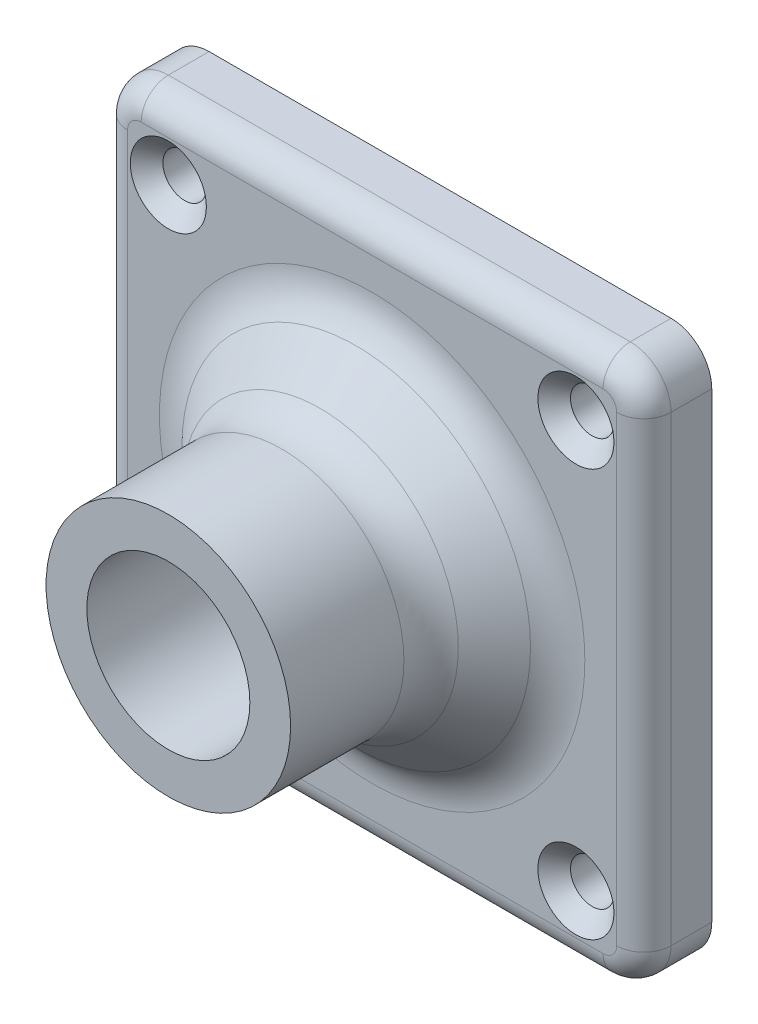
from build123d import *

# Parameters (mm, degrees)
SKETCH2_R           = 9
SKETCH2_R_2         = 6
BOSS_EXTRUDE1_DEPTH = 20
SKETCH3_R           = 6
BOSS_EXTRUDE2_DEPTH = 5
FILLET1_R           = 2
CUT_EXTRUDE1_REACH  = 7
SKETCH4_R           = 1.6
CHAMFER1_SIZE       = 5
FILLET2_R           = 4
CHAMFER2_SIZE       = 1.2


with BuildPart() as part:
    # Sketch2 → Boss-Extrude1 (new body)
    with BuildSketch(Plane.XY):
        with Locations((-135, -82.312657819)):
            Circle(SKETCH2_R)
        with Locations((-135, -82.312657819)):
            Circle(SKETCH2_R_2, mode=Mode.SUBTRACT)
    extrude(amount=BOSS_EXTRUDE1_DEPTH)

    # Sketch3 → Boss-Extrude2 (add)
    with BuildSketch(Plane(origin=(0, 0, 0), x_dir=(-1, 0, 0), z_dir=(0, 0, -1))):
        with BuildLine():
            Line((152, -102.312657819), (118, -102.312657819))
            ThreePointArc((118, -102.312657819), (115.878679656, -101.433978162), (115, -99.312657819))
            Line((115, -99.312657819), (115, -65.312657819))
            ThreePointArc((115, -65.312657819), (115.878679656, -63.191337475), (118, -62.312657819))
            Line((118, -62.312657819), (152, -62.312657819))
            ThreePointArc((152, -62.312657819), (154.121320344, -63.191337475), (155, -65.312657819))
            Line((155, -65.312657819), (155, -99.312657819))
            ThreePointArc((155, -99.312657819), (154.121320344, -101.433978162), (152, -102.312657819))
        make_face()
        with Locations((135, -82.312657819)):
            Circle(SKETCH3_R, mode=Mode.SUBTRACT)
    extrude(amount=-BOSS_EXTRUDE2_DEPTH)

    # Fillet1
    fillet1_edges = [part.edges().sort_by_distance(p)[0] for p in [
        (-115.878679656, -101.433978162, 5),
        (-115, -82.312657819, 5),
        (-115.878679656, -63.191337475, 5),
        (-135, -62.312657819, 5),
        (-154.121320344, -63.191337475, 5),
        (-155, -82.312657819, 5),
        (-154.121320344, -101.433978162, 5),
        (-135, -102.312657819, 5),
    ]]
    fillet(fillet1_edges, radius=FILLET1_R)

    # Sketch4 → Cut-Extrude1 (cut, up to next)
    with BuildSketch(Plane.XY.offset(5), mode=Mode.PRIVATE) as cut_extrude1_sk1:
        with Locations((-150, -67.312657819)):
            Circle(SKETCH4_R)
    cut_extrude1_tool1 = extrude(cut_extrude1_sk1.sketch, amount=-CUT_EXTRUDE1_REACH, mode=Mode.PRIVATE) & part.part
    add(cut_extrude1_tool1.solids().sort_by_distance((-150, -67.312658, 5))[0], mode=Mode.SUBTRACT)
    # Sketch4 → Cut-Extrude1 (cut, up to next)
    with BuildSketch(Plane.XY.offset(5), mode=Mode.PRIVATE) as cut_extrude1_sk2:
        with Locations((-120, -67.312657819)):
            Circle(SKETCH4_R)
    cut_extrude1_tool2 = extrude(cut_extrude1_sk2.sketch, amount=-CUT_EXTRUDE1_REACH, mode=Mode.PRIVATE) & part.part
    add(cut_extrude1_tool2.solids().sort_by_distance((-120, -67.312658, 5))[0], mode=Mode.SUBTRACT)
    # Sketch4 → Cut-Extrude1 (cut, up to next)
    with BuildSketch(Plane.XY.offset(5), mode=Mode.PRIVATE) as cut_extrude1_sk3:
        with Locations((-120, -97.312657819)):
            Circle(SKETCH4_R)
    cut_extrude1_tool3 = extrude(cut_extrude1_sk3.sketch, amount=-CUT_EXTRUDE1_REACH, mode=Mode.PRIVATE) & part.part
    add(cut_extrude1_tool3.solids().sort_by_distance((-120, -97.312658, 5))[0], mode=Mode.SUBTRACT)
    # Sketch4 → Cut-Extrude1 (cut, up to next)
    with BuildSketch(Plane.XY.offset(5), mode=Mode.PRIVATE) as cut_extrude1_sk4:
        with Locations((-150, -97.312657819)):
            Circle(SKETCH4_R)
    cut_extrude1_tool4 = extrude(cut_extrude1_sk4.sketch, amount=-CUT_EXTRUDE1_REACH, mode=Mode.PRIVATE) & part.part
    add(cut_extrude1_tool4.solids().sort_by_distance((-150, -97.312658, 5))[0], mode=Mode.SUBTRACT)

    # Chamfer1
    chamfer1_edges = [part.edges().sort_by_distance(p)[0] for p in [
        (-144, -82.312657819, 5),
    ]]
    chamfer(chamfer1_edges, length=CHAMFER1_SIZE)

    # Fillet2
    fillet2_edges = [part.edges().sort_by_distance(p)[0] for p in [
        (-144, -82.312657819, 10),
        (-149, -82.312657819, 5),
    ]]
    fillet(fillet2_edges, radius=FILLET2_R)

    # Chamfer2
    chamfer2_edges = [part.edges().sort_by_distance(p)[0] for p in [
        (-151.6, -97.312657819, 5),
        (-121.6, -97.312657819, 5),
        (-121.6, -67.312657819, 5),
        (-151.6, -67.312657819, 5),
    ]]
    chamfer(chamfer2_edges, length=CHAMFER2_SIZE)


solid = part.part
